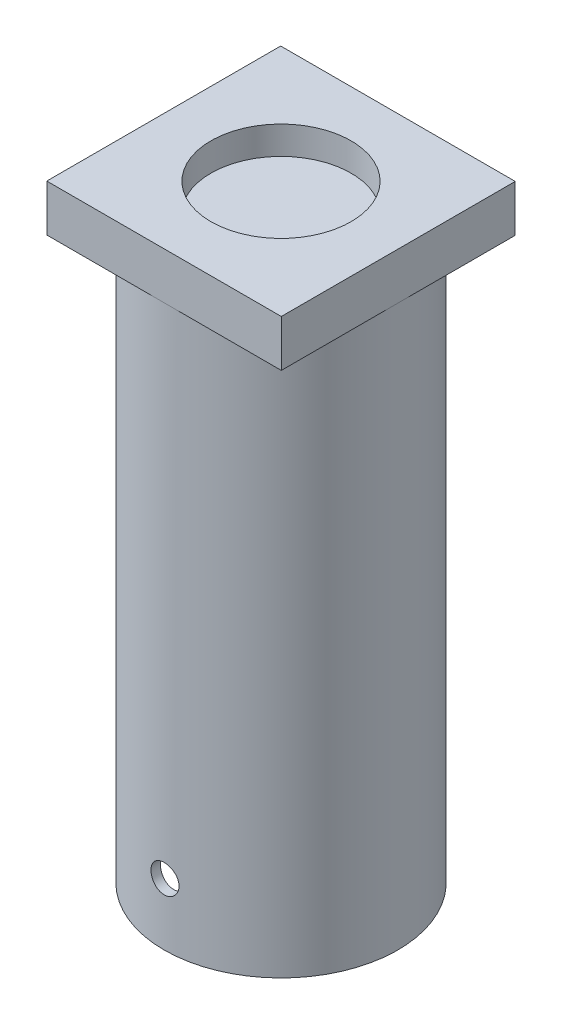
from build123d import *

# Parameters (mm, degrees)
SKETCH1_R           = 12.5
SKETCH1_R_2         = 11.5
BOSS_EXTRUDE1_DEPTH = 60
CUT_EXTRUDE1_REACH  = 14.5
SKETCH2_R           = 1.5
SKETCH3_W           = 25.097425704
SKETCH3_H           = 25.030895612
BOSS_EXTRUDE2_DEPTH = 5
SKETCH4_R           = 7.5
CUT_EXTRUDE2_DEPTH  = 3


with BuildPart() as part:
    # Sketch1 → Boss-Extrude1 (new body)
    with BuildSketch(Plane(origin=(0, 0, 0), x_dir=(1, 0, 0), z_dir=(0, 1, 0))):
        Circle(SKETCH1_R)
        Circle(SKETCH1_R_2, mode=Mode.SUBTRACT)
    extrude(amount=BOSS_EXTRUDE1_DEPTH)

    # Sketch2 → Cut-Extrude1 (cut, up to next)
    with BuildSketch(Plane.XY, mode=Mode.PRIVATE) as cut_extrude1_sk1:
        with Locations((0, 6.62)):
            Circle(SKETCH2_R)
    cut_extrude1_tool1 = extrude(cut_extrude1_sk1.sketch, amount=CUT_EXTRUDE1_REACH, mode=Mode.PRIVATE) & part.part
    add(cut_extrude1_tool1.solids().sort_by_distance((0, 6.62, 0))[0], mode=Mode.SUBTRACT)

    # Sketch3 → Boss-Extrude2 (add)
    with BuildSketch(Plane(origin=(0, 60, 0), x_dir=(1, 0, 0), z_dir=(0, 1, 0))):
        Rectangle(SKETCH3_W, SKETCH3_H)
    extrude(amount=BOSS_EXTRUDE2_DEPTH)

    # Sketch4 → Cut-Extrude2 (cut)
    with BuildSketch(Plane(origin=(0, 65, 0), x_dir=(1, 0, 0), z_dir=(0, 1, 0))):
        Circle(SKETCH4_R)
    extrude(amount=-CUT_EXTRUDE2_DEPTH, mode=Mode.SUBTRACT)


solid = part.part
